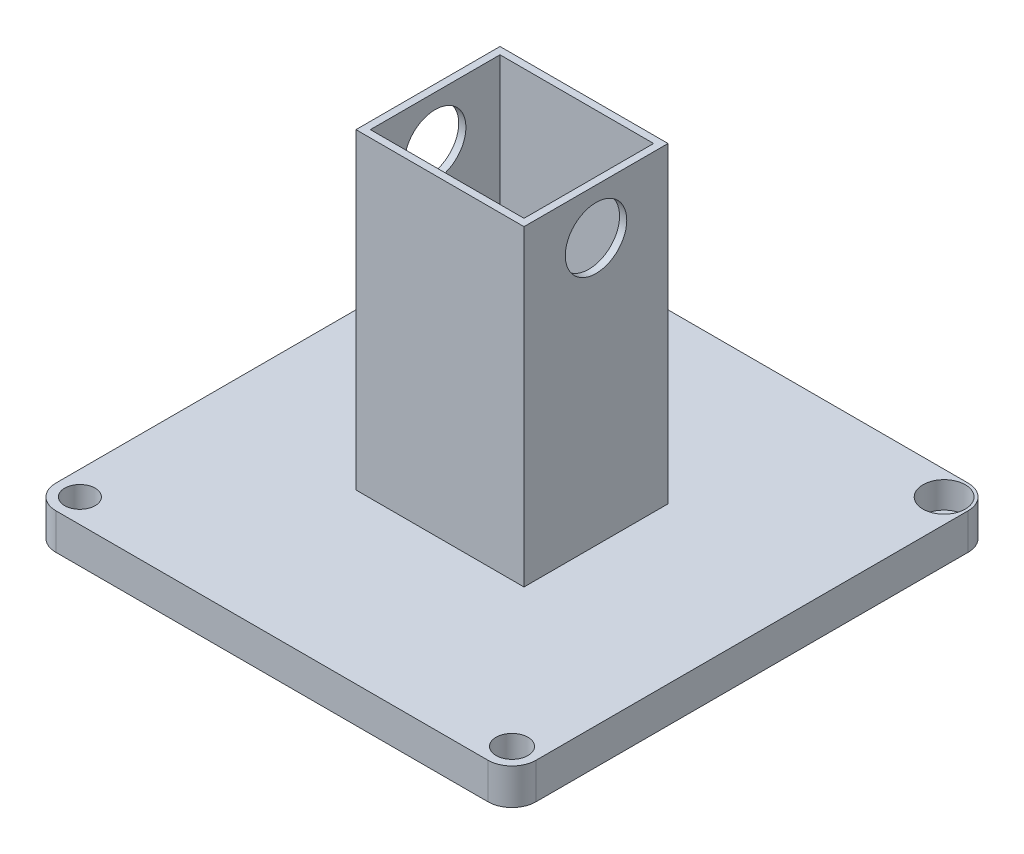
from build123d import *

# Parameters (mm, degrees)
SALIENTE_EXTRUIR1_DEPTH = 15
CROQUIS2_W              = 70
CROQUIS2_H              = 60
CROQUIS2_W_2            = 64
CROQUIS2_H_2            = 54
SALIENTE_EXTRUIR2_DEPTH = 130
CROQUIS3_R              = 12.804907533
CORTAR_EXTRUIR1_DEPTH   = 88
CROQUIS4_R              = 8.190031249
CROQUIS4_R_2            = 8.81355523
CROQUIS4_R_3            = 6.340285024
CROQUIS4_R_4            = 6.633362886
CORTAR_EXTRUIR2_DEPTH   = 11


with BuildPart() as part:
    # Croquis1 → Saliente-Extruir1 (new body)
    with BuildSketch(Plane(origin=(0, 0, 0), x_dir=(1, 0, 0), z_dir=(0, 1, 0))):
        with BuildLine():
            Line((-90, 100), (90, 100))
            ThreePointArc((90, 100), (97.071067812, 97.071067812), (100, 90))
            Line((100, 90), (100, -90))
            ThreePointArc((100, -90), (97.071067812, -97.071067812), (90, -100))
            Line((90, -100), (-90, -100))
            ThreePointArc((-90, -100), (-97.071067812, -97.071067812), (-100, -90))
            Line((-100, -90), (-100, 90))
            ThreePointArc((-100, 90), (-97.071067812, 97.071067812), (-90, 100))
        make_face()
    extrude(amount=SALIENTE_EXTRUIR1_DEPTH)

    # Croquis2 → Saliente-Extruir2 (add)
    with BuildSketch(Plane(origin=(0, 15, 0), x_dir=(1, 0, 0), z_dir=(0, 1, 0))):
        Rectangle(CROQUIS2_W, CROQUIS2_H)
        Rectangle(CROQUIS2_W_2, CROQUIS2_H_2, mode=Mode.SUBTRACT)
    extrude(amount=SALIENTE_EXTRUIR2_DEPTH)

    # Croquis3 → Cortar-Extruir1 (cut)
    with BuildSketch(Plane(origin=(35, 0, 0), x_dir=(0, 0, -1), z_dir=(1, 0, 0))):
        with Locations((0, 125.915041201)):
            Circle(CROQUIS3_R)
    extrude(amount=-CORTAR_EXTRUIR1_DEPTH, mode=Mode.SUBTRACT)

    # Croquis4 → Cortar-Extruir2 (cut)
    with BuildSketch(Plane(origin=(0, 15, 0), x_dir=(1, 0, 0), z_dir=(0, 1, 0))):
        with Locations((-90, 90)):
            Circle(CROQUIS4_R)
        with Locations((90, 90)):
            Circle(CROQUIS4_R_2)
        with Locations((-90, -90)):
            Circle(CROQUIS4_R_3)
        with Locations((90, -90)):
            Circle(CROQUIS4_R_4)
    extrude(amount=-CORTAR_EXTRUIR2_DEPTH, mode=Mode.SUBTRACT)


solid = part.part
